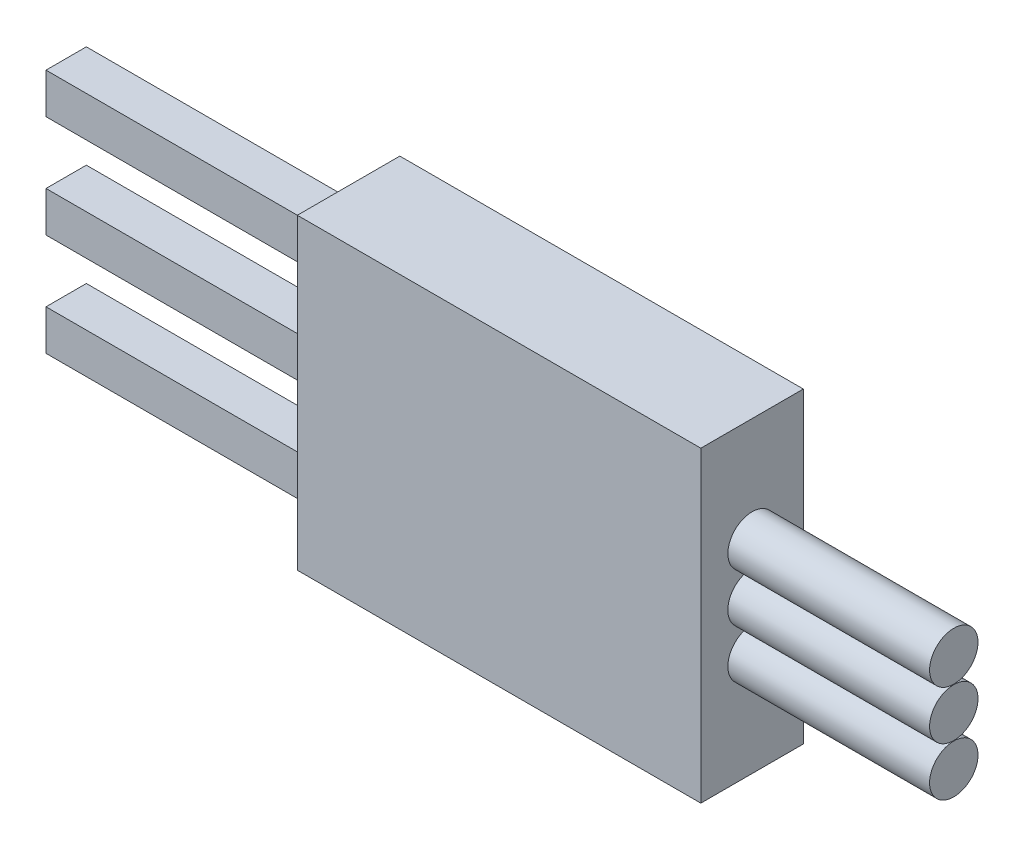
from build123d import *

# Parameters (mm, degrees)
CROQUIS5_W                = 7
CROQUIS5_H                = 1
SALIENTE_EXTRUIR1_DEPTH   = 1
SALIENTE_EXTRUIR1_2_DEPTH = 1
SALIENTE_EXTRUIR1_3_DEPTH = 1
CROQUIS14_W               = 2.54
CROQUIS14_H               = 7.62
SALIENTE_EXTRUIR2_DEPTH   = 10
CROQUIS16_R               = 0.6
SALIENTE_EXTRUIR4_DEPTH   = 5


with BuildPart() as part:
    # Croquis5 → Saliente-Extruir1 (new body)
    with BuildSketch(Plane.XY):
        with Locations((3.511240097, -1.933057617)):
            Rectangle(CROQUIS5_W, CROQUIS5_H)
    extrude(amount=SALIENTE_EXTRUIR1_DEPTH)



with BuildPart() as body_2:
    # Croquis5 → Saliente-Extruir1 2 (new body)
    with BuildSketch(Plane.XY):
        with Locations((3.511240097, 0.606942383)):
            Rectangle(CROQUIS5_W, CROQUIS5_H)
    extrude(amount=SALIENTE_EXTRUIR1_2_DEPTH)


with BuildPart() as body_3:
    # Croquis5 → Saliente-Extruir1 3 (new body)
    with BuildSketch(Plane.XY):
        with Locations((3.511240097, 3.146942383)):
            Rectangle(CROQUIS5_W, CROQUIS5_H)
    extrude(amount=SALIENTE_EXTRUIR1_3_DEPTH)


with BuildPart() as part_1:
    add(part.part)

    add(body_2.part)  # Saliente-Extruir2 merges body 2

    add(body_3.part)  # Saliente-Extruir2 merges body 3
    # Croquis14 → Saliente-Extruir2 (add)
    with BuildSketch(Plane(origin=(7.011240097, 0, 0), x_dir=(0, 0, -1), z_dir=(1, 0, 0))):
        with Locations((-0.5, 0.606942383)):
            Rectangle(CROQUIS14_W, CROQUIS14_H)
    extrude(amount=SALIENTE_EXTRUIR2_DEPTH)

    # Croquis16 → Saliente-Extruir4 (add)
    with BuildSketch(Plane(origin=(17.011240097, 0, 0), x_dir=(0, 0, -1), z_dir=(1, 0, 0))):
        with Locations((-0.5, 0.606942383)):
            Circle(CROQUIS16_R)
        with Locations((-0.5, 1.816942383)):
            Circle(CROQUIS16_R)
        with Locations((-0.5, -0.603057617)):
            Circle(CROQUIS16_R)
    extrude(amount=SALIENTE_EXTRUIR4_DEPTH)


solid = part_1.part
